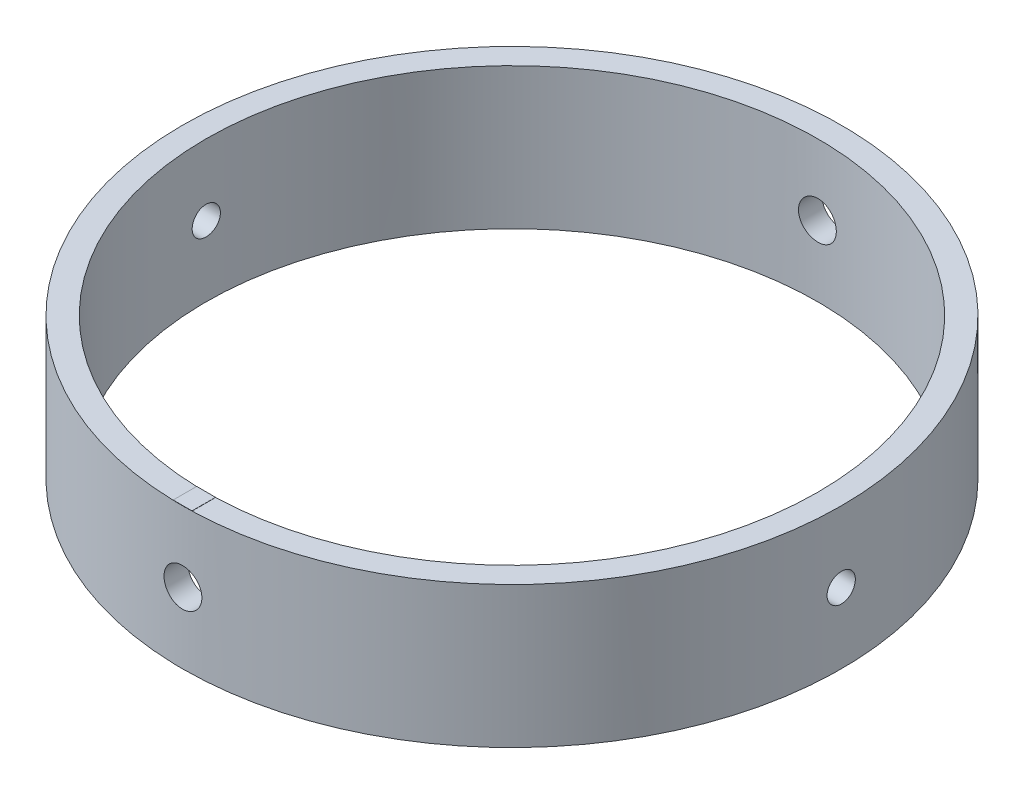
from build123d import *

# Parameters (mm, degrees)
SKETCH1_R                       = 44.45
SKETCH1_R_2                     = 41.275
BOSS_EXTRUDE1_DEPTH             = 19.05
SKETCH5_W                       = 2.5527
SKETCH5_H                       = 76.2
TAP_DRILL_FOR_1_4_20_TAP2_D     = 5.1054
TAP_DRILL_FOR_1_4_20_TAP2_DEPTH = 76.2
SKETCH10_R                      = 1.905
CUT_EXTRUDE3_DEPTH              = 77.2000001
CUT_EXTRUDE3_DEPTH_BACK         = 13.7000001
TIGWELD_W                       = 2.542332396
TIGWELD_H                       = 3.176399095
BOSS_EXTRUDE2_DEPTH             = 0.0254


with BuildPart() as part:
    # Sketch1 → Boss-Extrude1 (new body)
    with BuildSketch(Plane(origin=(0, 0, 0), x_dir=(1, 0, 0), z_dir=(0, 1, 0))):
        Circle(SKETCH1_R)
        Circle(SKETCH1_R_2, mode=Mode.SUBTRACT)
    extrude(amount=BOSS_EXTRUDE1_DEPTH)

    # Sketch5 → Tap Drill for 1/4-20 Tap1 (revolve, cut)
    with BuildSketch(Plane(origin=(0, 9.525, 31.75), x_dir=(0, -1, 0), z_dir=(1, 0, 0))):
        with Locations((1.27635, 38.1)):
            Rectangle(SKETCH5_W, SKETCH5_H)
    revolve(axis=Axis((0, 9.525, 38.1), (0, 0, -1)), mode=Mode.SUBTRACT)

    # Tap Drill for 1/4-20 Tap2
    with Locations(Plane(origin=(0, 0, -31.75), x_dir=(1, 0, 0), z_dir=(0, 0, -1))):
        with Locations((0, -9.525)):
            Hole(TAP_DRILL_FOR_1_4_20_TAP2_D / 2, depth=TAP_DRILL_FOR_1_4_20_TAP2_DEPTH)

    # Sketch10 → Cut-Extrude3 (cut, two sides)
    with BuildSketch(Plane(origin=(-31.75, 0, 0), x_dir=(0, 0, -1), z_dir=(1, 0, 0))) as cut_extrude3_sk:
        with Locations((0, 9.487883811)):
            Circle(SKETCH10_R)
    extrude(amount=CUT_EXTRUDE3_DEPTH, mode=Mode.SUBTRACT)
    extrude(cut_extrude3_sk.sketch, amount=-CUT_EXTRUDE3_DEPTH_BACK, mode=Mode.SUBTRACT)

    # TigWeld → Boss-Extrude2 (add)
    with BuildSketch(Plane(origin=(0, 19.05, 0), x_dir=(1, 0, 0), z_dir=(0, 1, 0))):
        with Locations((0, -42.843620543)):
            Rectangle(TIGWELD_W, TIGWELD_H)
    extrude(amount=BOSS_EXTRUDE2_DEPTH)


solid = part.part
